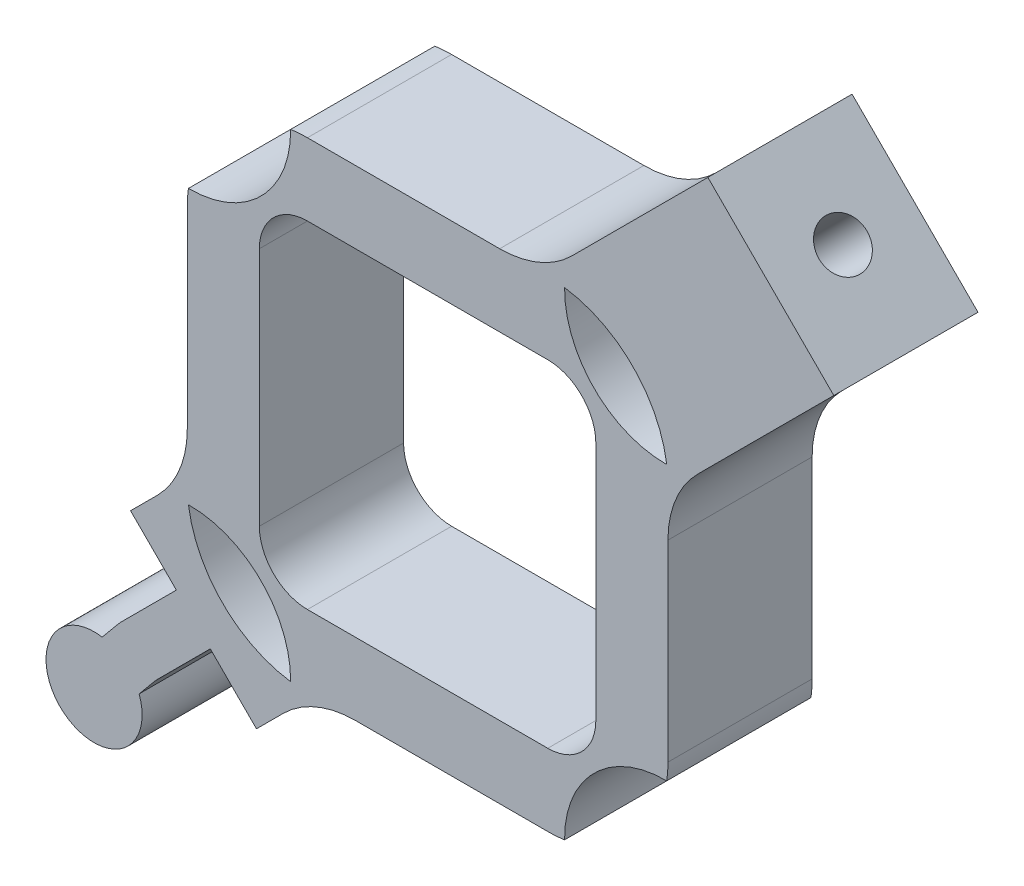
from build123d import *

# Parameters (mm, degrees)
EXTRUDE_1_DEPTH     = 3
SKETCH_4_W          = 3
SKETCH_4_H          = 3.704951288
EXTRUDE_3_DEPTH     = 1
CUT_EXTRUDE_2_REACH = 25.244
SKETCH_6_R          = 0.5
CUT_EXTRUDE_3_DEPTH = 3


with BuildPart() as part:
    # 草图1 → 凸台-拉伸1 (new body)
    with BuildSketch(Plane.XY):
        with BuildLine():
            ThreePointArc((-4.975392322, 2.84990406), (-4.993840493, 2.675384142), (-5, 2.5))
            Line((-5, 2.5), (-5, -1.5))
            ThreePointArc((-5, -1.5), (-5.161755993, -2.313202294), (-5.62239809, -3.00260191))
            Line((-5.62239809, -3.00260191), (-8.450825215, -5.831029035))
            Line((-8.450825215, -5.831029035), (-5.831029035, -8.450825215))
            Line((-5.831029035, -8.450825215), (-3.00260191, -5.62239809))
            ThreePointArc((-3.00260191, -5.62239809), (-2.313202294, -5.161755993), (-1.5, -5))
            Line((-1.5, -5), (2.5, -5))
            ThreePointArc((2.5, -5), (2.675384142, -4.993840493), (2.84990406, -4.975392322))
            ThreePointArc((2.84990406, -4.975392322), (3.464823228, -3.464823228), (4.975392322, -2.84990406))
            ThreePointArc((4.975392322, -2.84990406), (4.993840493, -2.675384142), (5, -2.5))
            Line((5, -2.5), (5, 1.5))
            ThreePointArc((5, 1.5), (5.161755993, 2.313202294), (5.62239809, 3.00260191))
            Line((5.62239809, 3.00260191), (8.450825215, 5.831029035))
            Line((8.450825215, 5.831029035), (5.831029035, 8.450825215))
            Line((5.831029035, 8.450825215), (3.00260191, 5.62239809))
            ThreePointArc((3.00260191, 5.62239809), (2.313202294, 5.161755993), (1.5, 5))
            Line((1.5, 5), (-2.5, 5))
            ThreePointArc((-2.5, 5), (-2.675384142, 4.993840493), (-2.84990406, 4.975392322))
            ThreePointArc((-2.84990406, 4.975392322), (-3.464823228, 3.464823228), (-4.975392322, 2.84990406))
        make_face()
        with BuildLine():
            ThreePointArc((4.975392322, 2.84990406), (3.464823228, 3.464823228), (2.84990406, 4.975392322))
            ThreePointArc((2.84990406, 4.975392322), (4.267766953, 4.267766953), (4.975392322, 2.84990406))
        make_face(mode=Mode.SUBTRACT)
        with BuildLine():
            ThreePointArc((-4.975392322, -2.84990406), (-3.464823228, -3.464823228), (-2.84990406, -4.975392322))
            ThreePointArc((-2.84990406, -4.975392322), (-4.267766953, -4.267766953), (-4.975392322, -2.84990406))
        make_face(mode=Mode.SUBTRACT)
        with BuildLine():
            ThreePointArc((-3.5, 2.5), (-3.207106781, 3.207106781), (-2.5, 3.5))
            Line((-2.5, 3.5), (2.5, 3.5))
            ThreePointArc((2.5, 3.5), (3.207106781, 3.207106781), (3.5, 2.5))
            Line((3.5, 2.5), (3.5, -2.5))
            ThreePointArc((3.5, -2.5), (3.207106781, -3.207106781), (2.5, -3.5))
            Line((2.5, -3.5), (-2.5, -3.5))
            ThreePointArc((-2.5, -3.5), (-3.207106781, -3.207106781), (-3.5, -2.5))
            Line((-3.5, -2.5), (-3.5, 2.5))
        make_face(mode=Mode.SUBTRACT)
    extrude(amount=EXTRUDE_1_DEPTH)

    # 草图4 → 凸台-拉伸3 (add)
    with BuildSketch(Plane(origin=(-7.140927125, -7.140927125, 0), x_dir=(0, 0, 1), z_dir=(-0.7071067811865472, -0.7071067811865479, 0))):
        with Locations((1.5, 0)):
            Rectangle(SKETCH_4_W, SKETCH_4_H)
    extrude(amount=EXTRUDE_3_DEPTH)

    # 草图6 → 切除-拉伸2 (cut, up to next)
    with BuildSketch(Plane(origin=(7.140927125, 7.140927125, 0), x_dir=(0, 0, -1), z_dir=(0.7071067811865476, 0.7071067811865476, 0)), mode=Mode.PRIVATE) as cut_extrude_2_sk1:
        with Locations((-1.5, 0)):
            Circle(SKETCH_6_R)
    cut_extrude_2_tool1 = extrude(cut_extrude_2_sk1.sketch, amount=-CUT_EXTRUDE_2_REACH, mode=Mode.PRIVATE) & part.part
    add(cut_extrude_2_tool1.solids().sort_by_distance((7.140927, 7.140927, 1.5))[0], mode=Mode.SUBTRACT)

    # 草图7 → 切除-拉伸3 (cut)
    with BuildSketch(Plane(origin=(0, 0, 0), x_dir=(-1, 0, 0), z_dir=(0, 0, -1))):
        with BuildLine():
            Line((6.001378676, -6.771192907), (5.682244672, -6.386285792))
            ThreePointArc((5.682244672, -6.386285792), (5.65169265, -6.351136109), (5.619537223, -6.317447019))
            Line((5.619537223, -6.317447019), (4.521052929, -5.218962725))
            Line((4.521052929, -5.218962725), (3.560109737, -6.179905917))
            Line((3.560109737, -6.179905917), (6.538135816, -9.157931996))
            Line((6.538135816, -9.157931996), (9.157931996, -6.538135816))
            Line((9.157931996, -6.538135816), (6.179905917, -3.560109737))
            Line((6.179905917, -3.560109737), (5.226626879, -4.513388774))
            Line((5.226626879, -4.513388774), (6.357997729, -5.644759624))
            ThreePointArc((6.357997729, -5.644759624), (6.40623087, -5.695293259), (6.452058903, -5.748017783))
            Line((6.452058903, -5.748017783), (6.771192907, -6.132924899))
            ThreePointArc((6.771192907, -6.132924899), (7.57731011, -7.888551813), (6.001378676, -6.771192907))
        make_face()
    extrude(amount=-CUT_EXTRUDE_3_DEPTH, mode=Mode.SUBTRACT)


solid = part.part
